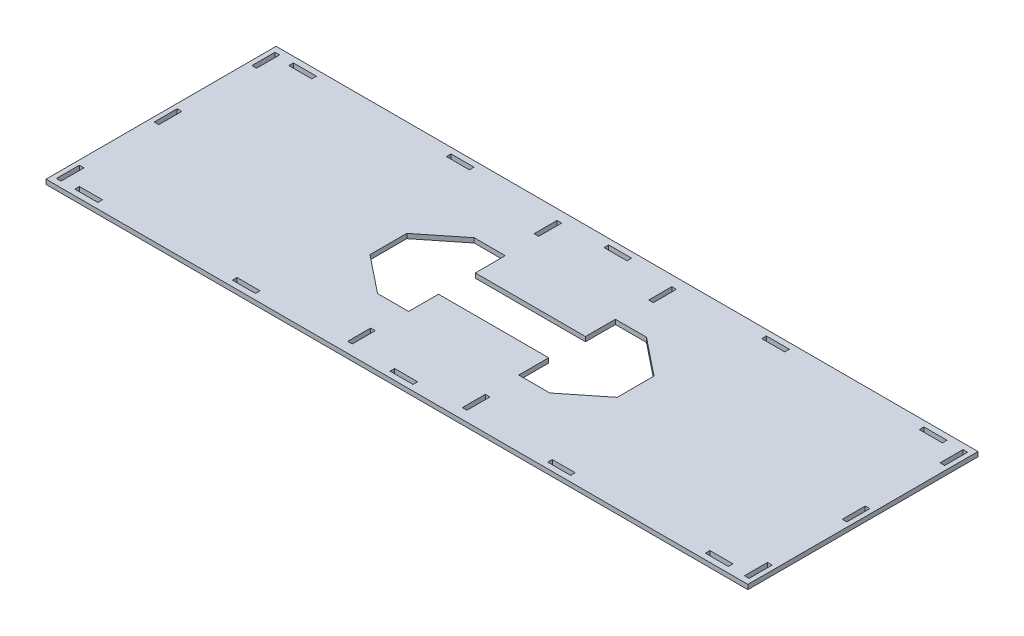
from build123d import *

# Parameters (mm, degrees)
SKETCH1_W           = 610
SKETCH1_H           = 200
SKETCH1_W_2         = 4
SKETCH1_H_2         = 20
SKETCH1_W_3         = 20
SKETCH1_H_3         = 4
BOSS_EXTRUDE1_DEPTH = 4
CUT_EXTRUDE1_DEPTH  = 10


with BuildPart() as part:
    # Sketch1 → Boss-Extrude1 (new body)
    with BuildSketch(Plane(origin=(0, 0, 0), x_dir=(1, 0, 0), z_dir=(0, 1, 0))):
        Rectangle(SKETCH1_W, SKETCH1_H)
        with Locations((-299, -85)):
            Rectangle(SKETCH1_W_2, SKETCH1_H_2, mode=Mode.SUBTRACT)
        with Locations((-299, 85)):
            Rectangle(SKETCH1_W_2, SKETCH1_H_2, mode=Mode.SUBTRACT)
        with Locations((-299, 0)):
            Rectangle(SKETCH1_W_2, SKETCH1_H_2, mode=Mode.SUBTRACT)
        with Locations((-275, 93)):
            Rectangle(SKETCH1_W_3, SKETCH1_H_3, mode=Mode.SUBTRACT)
        with Locations((-138, 93)):
            Rectangle(SKETCH1_W_3, SKETCH1_H_3, mode=Mode.SUBTRACT)
        with Locations((-1, 93)):
            Rectangle(SKETCH1_W_3, SKETCH1_H_3, mode=Mode.SUBTRACT)
        with Locations((-1, -93)):
            Rectangle(SKETCH1_W_3, SKETCH1_H_3, mode=Mode.SUBTRACT)
        with Locations((-138, -93)):
            Rectangle(SKETCH1_W_3, SKETCH1_H_3, mode=Mode.SUBTRACT)
        with Locations((-275, -93)):
            Rectangle(SKETCH1_W_3, SKETCH1_H_3, mode=Mode.SUBTRACT)
        with Locations((-49.859697176, -81)):
            Rectangle(SKETCH1_W_2, SKETCH1_H_2, mode=Mode.SUBTRACT)
        with Locations((-49.859697176, -32)):
            Rectangle(SKETCH1_W_2, SKETCH1_H_2, mode=Mode.SUBTRACT)
        with Locations((-64.859697176, -14)):
            Rectangle(SKETCH1_W_3, SKETCH1_H_3, mode=Mode.SUBTRACT)
        with Locations((-64.859697176, 14)):
            Rectangle(SKETCH1_W_3, SKETCH1_H_3, mode=Mode.SUBTRACT)
        with Locations((-49.859697176, 32)):
            Rectangle(SKETCH1_W_2, SKETCH1_H_2, mode=Mode.SUBTRACT)
        with Locations((0, -14)):
            Rectangle(SKETCH1_W_3, SKETCH1_H_3, mode=Mode.SUBTRACT)
        with Locations((0.140302824, 14)):
            Rectangle(SKETCH1_W_3, SKETCH1_H_3, mode=Mode.SUBTRACT)
        with Locations((136, 93)):
            Rectangle(SKETCH1_W_3, SKETCH1_H_3, mode=Mode.SUBTRACT)
        with Locations((273, 93)):
            Rectangle(SKETCH1_W_3, SKETCH1_H_3, mode=Mode.SUBTRACT)
        with Locations((49.859697176, -81)):
            Rectangle(SKETCH1_W_2, SKETCH1_H_2, mode=Mode.SUBTRACT)
        with Locations((49.859697176, -32)):
            Rectangle(SKETCH1_W_2, SKETCH1_H_2, mode=Mode.SUBTRACT)
        with Locations((64.859697176, -14)):
            Rectangle(SKETCH1_W_3, SKETCH1_H_3, mode=Mode.SUBTRACT)
        with Locations((64.859697176, 14)):
            Rectangle(SKETCH1_W_3, SKETCH1_H_3, mode=Mode.SUBTRACT)
        with Locations((49.859697176, 32)):
            Rectangle(SKETCH1_W_2, SKETCH1_H_2, mode=Mode.SUBTRACT)
        with Locations((273, -93)):
            Rectangle(SKETCH1_W_3, SKETCH1_H_3, mode=Mode.SUBTRACT)
        with Locations((136, -93)):
            Rectangle(SKETCH1_W_3, SKETCH1_H_3, mode=Mode.SUBTRACT)
        with Locations((49.859697176, 81)):
            Rectangle(SKETCH1_W_2, SKETCH1_H_2, mode=Mode.SUBTRACT)
        with Locations((-49.859697176, 81)):
            Rectangle(SKETCH1_W_2, SKETCH1_H_2, mode=Mode.SUBTRACT)
        with Locations((299, 85)):
            Rectangle(SKETCH1_W_2, SKETCH1_H_2, mode=Mode.SUBTRACT)
        with Locations((299, 0)):
            Rectangle(SKETCH1_W_2, SKETCH1_H_2, mode=Mode.SUBTRACT)
        with Locations((299, -85)):
            Rectangle(SKETCH1_W_2, SKETCH1_H_2, mode=Mode.SUBTRACT)
    extrude(amount=BOSS_EXTRUDE1_DEPTH)

    # Sketch2 → Cut-Extrude1 (cut)
    with BuildSketch(Plane(origin=(0, 4, 0), x_dir=(1, 0, 0), z_dir=(0, 1, 0))):
        Polygon((-47.859697176, 16), (47.859697176, 16), (47.859697176, 42), (74.859697176, 42), (107.419236847, 16), (107.419236847, -16), (74.859697176, -42), (47.859697176, -42), (47.859697176, -16), (-47.859697176, -16), (-47.859697176, -42), (-74.859697176, -42), (-107.419236847, -16), (-107.419236847, 16), (-74.859697176, 42), (-47.859697176, 42), align=None)
    extrude(amount=-CUT_EXTRUDE1_DEPTH, mode=Mode.SUBTRACT)


solid = part.part
